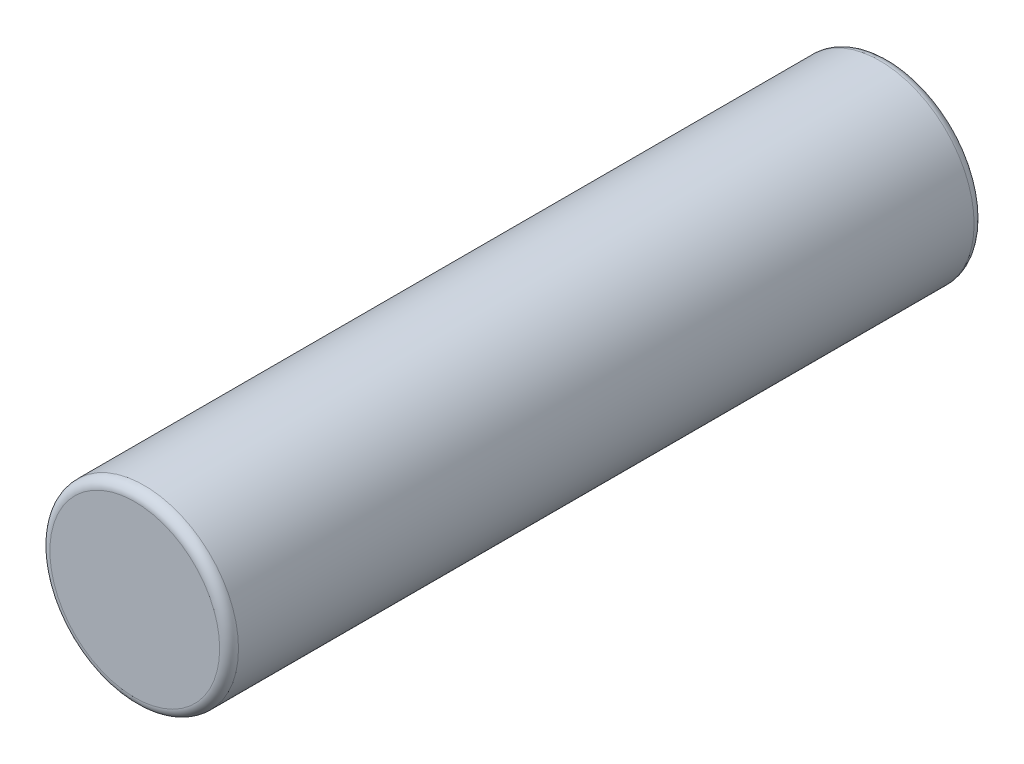
from build123d import *

# Parameters (mm, degrees)
SKETCH1_R           = 20
BOSS_EXTRUDE1_DEPTH = 160
FILLET1_R           = 2


with BuildPart() as part:
    # Sketch1 → Boss-Extrude1 (new body)
    with BuildSketch(Plane.XY):
        Circle(SKETCH1_R)
    extrude(amount=BOSS_EXTRUDE1_DEPTH)

    # Fillet1
    fillet1_edges = [part.edges().sort_by_distance(p)[0] for p in [
        (-20, 0, 0),
        (-20, 0, 160),
    ]]
    fillet(fillet1_edges, radius=FILLET1_R)


solid = part.part
